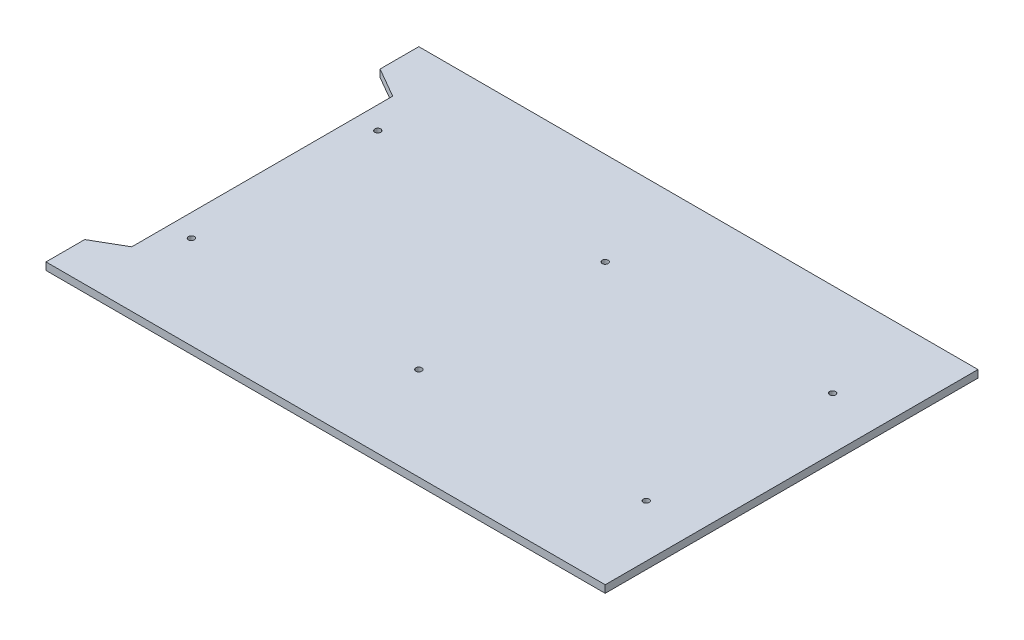
from build123d import *

# Parameters (mm, degrees)
SKETCH1_W           = 750
SKETCH1_H           = 500
BOSS_EXTRUDE1_DEPTH = 10
SKETCH2_R           = 4
CUT_EXTRUDE1_DEPTH  = 10
SKETCH3_R           = 4
CUT_EXTRUDE2_DEPTH  = 10
SKETCH4_R           = 4
CUT_EXTRUDE3_DEPTH  = 10
SKETCH5_R           = 4
CUT_EXTRUDE4_DEPTH  = 10
SKETCH6_R           = 4
CUT_EXTRUDE5_DEPTH  = 10
SKETCH7_R           = 4
CUT_EXTRUDE6_DEPTH  = 10
CUT_EXTRUDE7_REACH  = 12


with BuildPart() as part:
    # Sketch1 → Boss-Extrude1 (new body)
    with BuildSketch(Plane(origin=(0, 0, 0), x_dir=(1, 0, 0), z_dir=(0, 1, 0))):
        Rectangle(SKETCH1_W, SKETCH1_H)
    extrude(amount=BOSS_EXTRUDE1_DEPTH)

    # Sketch2 → Cut-Extrude1 (cut)
    with BuildSketch(Plane(origin=(0, 10, 0), x_dir=(1, 0, 0), z_dir=(0, 1, 0))):
        with Locations((305, 125)):
            Circle(SKETCH2_R)
    extrude(amount=-CUT_EXTRUDE1_DEPTH, mode=Mode.SUBTRACT)

    # Sketch3 → Cut-Extrude2 (cut)
    with BuildSketch(Plane(origin=(0, 10, 0), x_dir=(1, 0, 0), z_dir=(0, 1, 0))):
        with Locations((305, -125)):
            Circle(SKETCH3_R)
    extrude(amount=-CUT_EXTRUDE2_DEPTH, mode=Mode.SUBTRACT)

    # Sketch4 → Cut-Extrude3 (cut)
    with BuildSketch(Plane(origin=(0, 10, 0), x_dir=(1, 0, 0), z_dir=(0, 1, 0))):
        with Locations((0, 125)):
            Circle(SKETCH4_R)
    extrude(amount=-CUT_EXTRUDE3_DEPTH, mode=Mode.SUBTRACT)

    # Sketch5 → Cut-Extrude4 (cut)
    with BuildSketch(Plane(origin=(0, 10, 0), x_dir=(1, 0, 0), z_dir=(0, 1, 0))):
        with Locations((0, -125)):
            Circle(SKETCH5_R)
    extrude(amount=-CUT_EXTRUDE4_DEPTH, mode=Mode.SUBTRACT)

    # Sketch6 → Cut-Extrude5 (cut)
    with BuildSketch(Plane(origin=(0, 10, 0), x_dir=(1, 0, 0), z_dir=(0, 1, 0))):
        with Locations((-305, 125)):
            Circle(SKETCH6_R)
    extrude(amount=-CUT_EXTRUDE5_DEPTH, mode=Mode.SUBTRACT)

    # Sketch7 → Cut-Extrude6 (cut)
    with BuildSketch(Plane(origin=(0, 10, 0), x_dir=(1, 0, 0), z_dir=(0, 1, 0))):
        with Locations((-305, -125)):
            Circle(SKETCH7_R)
    extrude(amount=-CUT_EXTRUDE6_DEPTH, mode=Mode.SUBTRACT)

    # Sketch10 → Cut-Extrude7 (cut, up to next)
    with BuildSketch(Plane(origin=(0, 10, 0), x_dir=(1, 0, 0), z_dir=(0, 1, 0)), mode=Mode.PRIVATE) as cut_extrude7_sk1:
        Polygon((-335, 175), (-335, -175), (-375, -198.094010768), (-375, 198.094010768), align=None)
    cut_extrude7_tool1 = extrude(cut_extrude7_sk1.sketch, amount=-CUT_EXTRUDE7_REACH, mode=Mode.PRIVATE) & part.part
    add(cut_extrude7_tool1.solids().sort_by_distance((-355.412658, 10, 0))[0], mode=Mode.SUBTRACT)


solid = part.part
